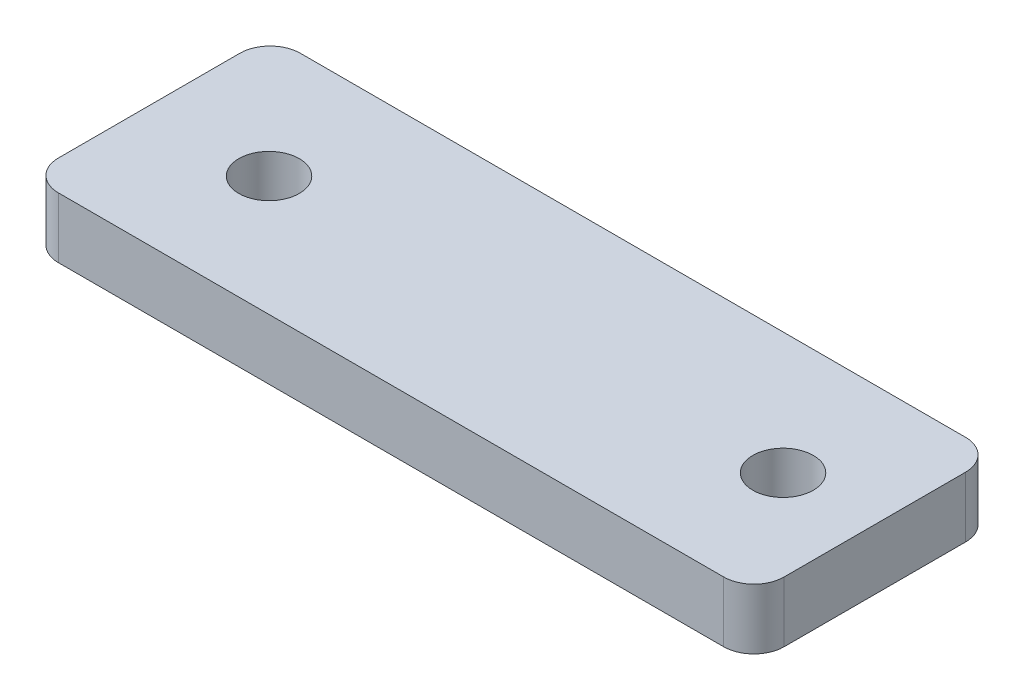
from build123d import *

# Parameters (mm, degrees)
SKETCH1_R           = 5
BOSS_EXTRUDE1_DEPTH = 10


with BuildPart() as part:
    # Sketch1 → Boss-Extrude1 (new body)
    with BuildSketch(Plane(origin=(0, 0, 0), x_dir=(1, 0, 0), z_dir=(0, 1, 0))):
        with BuildLine():
            Line((-40.871998364, 15.475635224), (69.128001636, 15.475635224))
            ThreePointArc((69.128001636, 15.475635224), (72.663535542, 14.011169129), (74.128001636, 10.475635224))
            Line((74.128001636, 10.475635224), (74.128001636, -19.524364776))
            ThreePointArc((74.128001636, -19.524364776), (72.663535542, -23.059898682), (69.128001636, -24.524364776))
            Line((69.128001636, -24.524364776), (-40.871998364, -24.524364776))
            ThreePointArc((-40.871998364, -24.524364776), (-44.40753227, -23.059898682), (-45.871998364, -19.524364776))
            Line((-45.871998364, -19.524364776), (-45.871998364, 10.475635224))
            ThreePointArc((-45.871998364, 10.475635224), (-44.40753227, 14.011169129), (-40.871998364, 15.475635224))
        make_face()
        with Locations((-25.871998364, -4.701562159)):
            Circle(SKETCH1_R, mode=Mode.SUBTRACT)
        with Locations((59.128001636, -4.701562159)):
            Circle(SKETCH1_R, mode=Mode.SUBTRACT)
    extrude(amount=BOSS_EXTRUDE1_DEPTH)


solid = part.part
